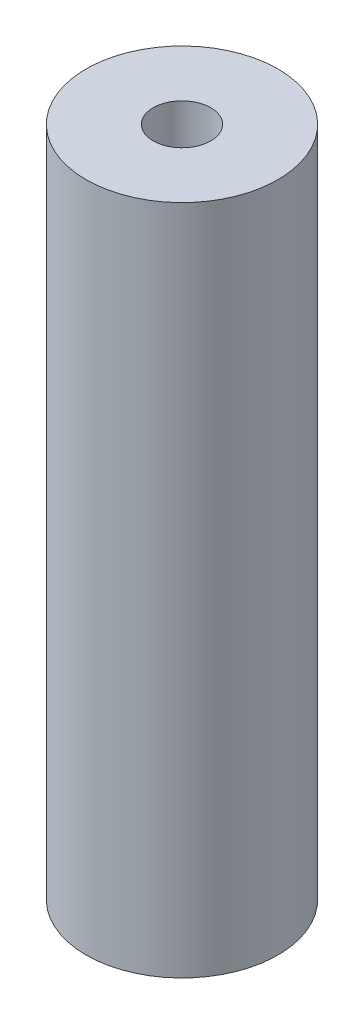
from build123d import *

# Parameters (mm, degrees)
SKETCH2_R           = 5
SKETCH2_R_2         = 1.5
BOSS_EXTRUDE1_DEPTH = 35


with BuildPart() as part:
    # Sketch2 → Boss-Extrude1 (new body)
    with BuildSketch(Plane(origin=(0, 0, 0), x_dir=(1, 0, 0), z_dir=(0, 1, 0))):
        Circle(SKETCH2_R)
        Circle(SKETCH2_R_2, mode=Mode.SUBTRACT)
    extrude(amount=BOSS_EXTRUDE1_DEPTH)


solid = part.part
